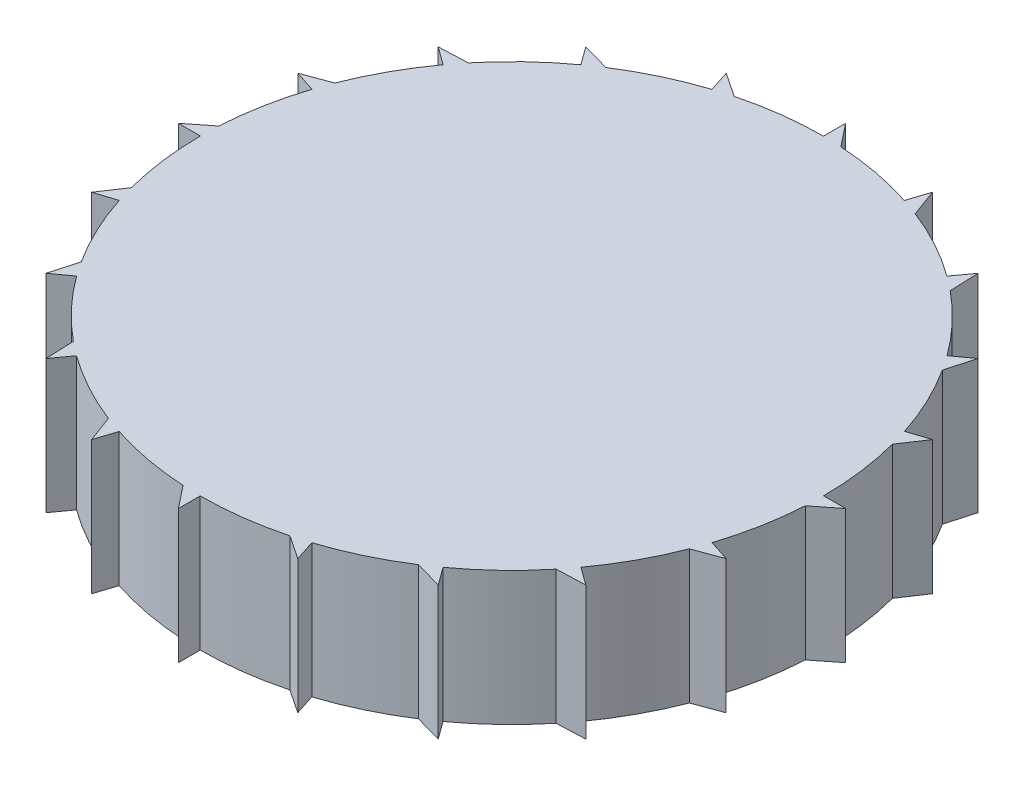
from build123d import *

# Parameters (mm, degrees)
SKETCH1_R           = 70
BOSS_EXTRUDE1_DEPTH = 30
BOSS_EXTRUDE2_DEPTH = 30
BOSS_EXTRUDE3_DEPTH = 30
CIRPATTERN1_COUNT   = 20


with BuildPart() as part:
    # Sketch1 → Boss-Extrude1 (new body)
    with BuildSketch(Plane(origin=(0, 0, 0), x_dir=(1, 0, 0), z_dir=(0, 1, 0))):
        Circle(SKETCH1_R)
    extrude(amount=BOSS_EXTRUDE1_DEPTH)

    # Sketch2 → Boss-Extrude2 (add)
    with BuildSketch(Plane(origin=(0, 0, 0), x_dir=(1, 0, 0), z_dir=(0, 1, 0))):
        Polygon((-5, 0), (5, 0), (5, 10), (0, 18.9908378), (-5, 10), align=None)
    extrude(amount=-BOSS_EXTRUDE2_DEPTH)

    # Sketch3 → Boss-Extrude3 (add)
    with BuildSketch(Plane(origin=(0, 30, 0), x_dir=(1, 0, 0), z_dir=(0, 1, 0))):
        with BuildLine():
            Line((0, 75), (0, 70))
            ThreePointArc((0, 70), (2.021982695, 69.970790949), (4.042277957, 69.883188171))
            Line((4.042277957, 69.883188171), (0, 75))
        make_face()
    boss_extrude3 = extrude(amount=-BOSS_EXTRUDE3_DEPTH)

    # CirPattern1: Boss-Extrude3 ×20 about axis
    cirpattern1_axis = Axis((0.000873645, 0, -0.046633798), (0, 1, 0))
    for i in range(1, CIRPATTERN1_COUNT):
        add(boss_extrude3.rotate(cirpattern1_axis, i * 360 / CIRPATTERN1_COUNT))


solid = part.part
